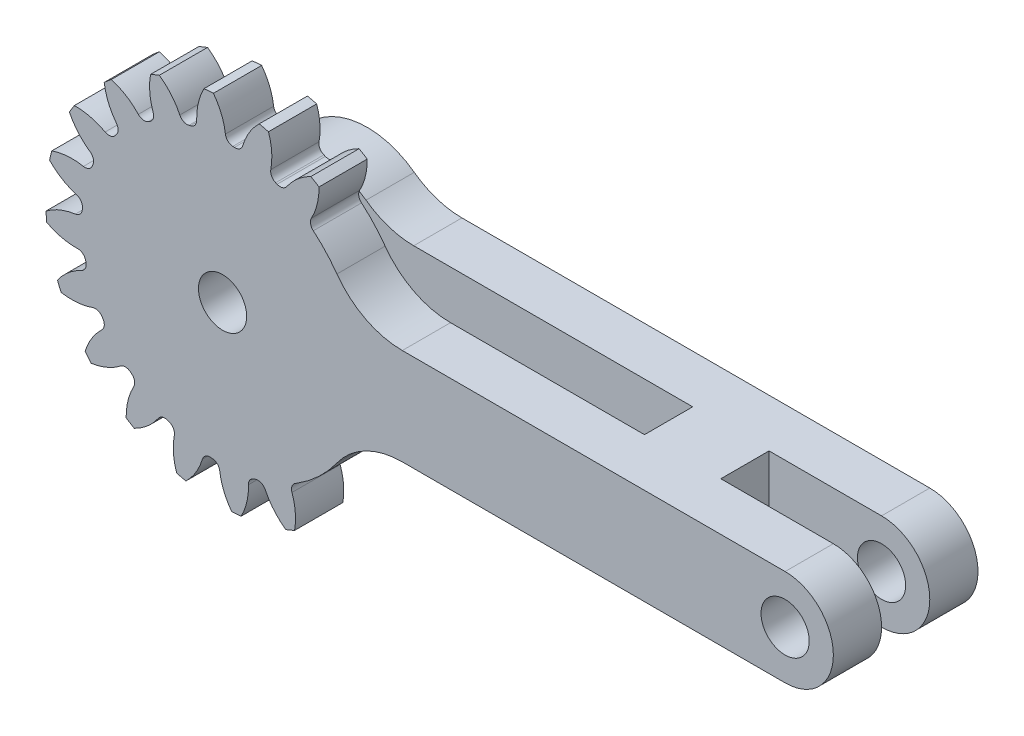
from build123d import *

# Parameters (mm, degrees)
ESTRUSIONE_ESTRUSIONE1_DEPTH         = 4.5
ESTRUSIONE_ESTRUSIONE1_DEPTH_BACK    = 4.5
SCHIZZO2_R                           = 8.75
SCHIZZO2_R_2                         = 1.5
ESTRUSIONE_ESTRUSIONE2_DEPTH         = 4.5
RACCORDO1_R                          = 0.5
RACCORDO2_R                          = 0.5
RIPETIZIONECIRCOLARE1_COUNT          = 20
RACCORDO1_OF_RIPETIZIONECIRCOLARE1_R = 0.5
RACCORDO2_OF_RIPETIZIONECIRCOLARE1_R = 0.5
ESTRUSIONE_ESTRUSIONE4_DEPTH         = 4.5
ESTRUSIONE_ESTRUSIONE4_DEPTH_BACK    = 4.5
SCHIZZO1_R                           = 1.5
TAGLIO_ESTRUSIONE2_DEPTH             = 15
TAGLIO_ESTRUSIONE2_DEPTH_BACK        = 15
SCHIZZO8_W                           = 10
SCHIZZO8_H                           = 3
SCHIZZO8_W_2                         = 35
TAGLIO_ESTRUSIONE3_DEPTH             = 3.3
TAGLIO_ESTRUSIONE4_START             = -3.3
TAGLIO_ESTRUSIONE4_DEPTH             = 3.3
RACCORDO3_R                          = 5
RACCORDO4_R                          = 5
RACCORDO5_R                          = 5
RACCORDO6_R                          = 5


with BuildPart() as part:
    # Schizzo2 → Estrusione-Estrusione1 (new, two sides: drawn at the far end of the back side and taken through both)
    with BuildSketch(Plane.XY.offset(-ESTRUSIONE_ESTRUSIONE1_DEPTH_BACK)):
        Circle(SCHIZZO2_R)
        Circle(SCHIZZO2_R_2, mode=Mode.SUBTRACT)
    extrude(amount=ESTRUSIONE_ESTRUSIONE1_DEPTH + ESTRUSIONE_ESTRUSIONE1_DEPTH_BACK)

    # Schizzo3 → Estrusione-Estrusione2 (add)
    with BuildSketch(Plane.XY):
        with BuildLine():
            ThreePointArc((-8.747468803, 0.210450818), (-8.72302667, -0.686517088), (-8.606851185, -1.576265422))
            ThreePointArc((-8.606851185, -1.576265422), (-9.80578703, -1.55009332), (-10.938929077, -1.157510536))
            ThreePointArc((-10.938929077, -1.157510536), (-10.966090671, -0.863050053), (-10.98532725, -0.567965858))
            ThreePointArc((-10.98532725, -0.567965858), (-9.927549539, -0.00295395), (-8.747468803, 0.210450818))
        make_face()
    estrusione_estrusione2 = extrude(amount=ESTRUSIONE_ESTRUSIONE2_DEPTH)

    # Raccordo1
    raccordo1_edges = [part.edges().sort_by_distance(p)[0] for p in [
        (-8.747468803, 0.210450818, 2.25),
    ]]
    fillet(raccordo1_edges, radius=RACCORDO1_R)

    # Raccordo2
    raccordo2_edges = [part.edges().sort_by_distance(p)[0] for p in [
        (-8.606851185, -1.576265422, 2.25),
    ]]
    fillet(raccordo2_edges, radius=RACCORDO2_R)

    # RipetizioneCircolare1: Estrusione-Estrusione2 ×20 about axis
    ripetizionecircolare1_axis = Axis((0, 0, -4.5), (0, 0, 1))
    for i in range(1, RIPETIZIONECIRCOLARE1_COUNT):
        add(estrusione_estrusione2.rotate(ripetizionecircolare1_axis, i * 360 / RIPETIZIONECIRCOLARE1_COUNT))

    # Raccordo1 of RipetizioneCircolare1
    raccordo1_of_ripetizionecircolare1_edges = [part.edges().sort_by_distance(p)[0] for p in [
        (-8.384370085, -2.502965896, 2.25),
        (-7.200550806, -4.971374869, 2.25),
        (-5.311891446, -6.953151032, 2.25),
        (-2.90326714, -8.254304326, 2.25),
        (-0.210450818, -8.747468803, 2.25),
        (2.502965896, -8.384370085, 2.25),
        (4.971374869, -7.200550806, 2.25),
        (6.953151032, -5.311891446, 2.25),
        (8.254304326, -2.90326714, 2.25),
        (8.747468803, -0.210450818, 2.25),
        (8.384370085, 2.502965896, 2.25),
        (7.200550806, 4.971374869, 2.25),
        (5.311891446, 6.953151032, 2.25),
        (2.90326714, 8.254304326, 2.25),
        (0.210450818, 8.747468803, 2.25),
        (-2.502965896, 8.384370085, 2.25),
        (-4.971374869, 7.200550806, 2.25),
        (-6.953151032, 5.311891446, 2.25),
        (-8.254304326, 2.90326714, 2.25),
    ]]
    fillet(raccordo1_of_ripetizionecircolare1_edges, radius=RACCORDO1_OF_RIPETIZIONECIRCOLARE1_R)

    # Raccordo2 of RipetizioneCircolare1
    raccordo2_of_ripetizionecircolare1_edges = [part.edges().sort_by_distance(p)[0] for p in [
        (-7.698509101, -4.158780785, 2.25),
        (-6.036583308, -6.334205709, 2.25),
        (-3.783754681, -7.889594445, 2.25),
        (-1.160545783, -8.672694707, 2.25),
        (1.576265422, -8.606851185, 2.25),
        (4.158780785, -7.698509101, 2.25),
        (6.334205709, -6.036583308, 2.25),
        (7.889594445, -3.783754681, 2.25),
        (8.672694707, -1.160545783, 2.25),
        (8.606851185, 1.576265422, 2.25),
        (7.698509101, 4.158780785, 2.25),
        (6.036583308, 6.334205709, 2.25),
        (3.783754681, 7.889594445, 2.25),
        (1.160545783, 8.672694707, 2.25),
        (-1.576265422, 8.606851185, 2.25),
        (-4.158780785, 7.698509101, 2.25),
        (-6.334205709, 6.036583308, 2.25),
        (-7.889594445, 3.783754681, 2.25),
        (-8.672694707, 1.160545783, 2.25),
    ]]
    fillet(raccordo2_of_ripetizionecircolare1_edges, radius=RACCORDO2_OF_RIPETIZIONECIRCOLARE1_R)

    # Schizzo1 → Estrusione-Estrusione4 (add, two sides: drawn at the far end of the back side and taken through both)
    with BuildSketch(Plane.XY.offset(-ESTRUSIONE_ESTRUSIONE4_DEPTH_BACK)):
        with BuildLine():
            ThreePointArc((35, -3), (38, 0), (35, 3))
            Line((35, 3), (0, 3))
            ThreePointArc((0, 3), (-3, 0), (0, -3))
            Line((0, -3), (35, -3))
        make_face()
        Circle(SCHIZZO1_R, mode=Mode.SUBTRACT)
        with Locations((35, 0)):
            Circle(SCHIZZO1_R, mode=Mode.SUBTRACT)
    extrude(amount=ESTRUSIONE_ESTRUSIONE4_DEPTH + ESTRUSIONE_ESTRUSIONE4_DEPTH_BACK)

    # Schizzo8 → Taglio-Estrusione2 (cut, two sides: drawn at the far end of the back side and taken through both)
    with BuildSketch(Plane(origin=(0, 3, 0), x_dir=(1, 0, 0), z_dir=(0, 1, 0)).offset(-TAGLIO_ESTRUSIONE2_DEPTH_BACK)):
        with Locations((33, 0)):
            Rectangle(SCHIZZO8_W, SCHIZZO8_H)
        with Locations((5.75, 0)):
            Rectangle(SCHIZZO8_W_2, SCHIZZO8_H)
    extrude(amount=TAGLIO_ESTRUSIONE2_DEPTH + TAGLIO_ESTRUSIONE2_DEPTH_BACK, mode=Mode.SUBTRACT)

    # Schizzo9 → Taglio-Estrusione3 (cut)
    with BuildSketch(Plane(origin=(0, 0, -4.5), x_dir=(-1, 0, 0), z_dir=(0, 0, -1))):
        with BuildLine():
            Line((-8.219641111, 3), (-3.919641111, 3))
            ThreePointArc((-3.919641111, 3), (4.935948383, 0), (-3.919641111, -3))
            Line((-3.919641111, -3), (-8.219641111, -3))
            ThreePointArc((-8.219641111, -3), (8.75, 0), (-8.219641111, 3))
        make_face()
    extrude(amount=-TAGLIO_ESTRUSIONE3_DEPTH, mode=Mode.SUBTRACT)

    # Schizzo10 → Taglio-Estrusione4 (cut)
    with BuildSketch(Plane.XY.offset(4.5).offset(TAGLIO_ESTRUSIONE4_START)):
        with BuildLine():
            Line((9.344633641, 3), (8.219641111, 3))
            ThreePointArc((8.219641111, 3), (7.201030237, 4.970680388), (5.719564246, 6.621864151))
            Line((5.719564246, 6.621864151), (8.634121218, 8.480947468))
            Line((8.634121218, 8.480947468), (11.50497977, 3.980191244))
            Line((11.50497977, 3.980191244), (9.344633641, 3))
        make_face()
        with BuildLine():
            Line((4.624902836, -7.427837758), (6.162751299, -9.897703457))
            Line((6.162751299, -9.897703457), (11.50497977, -6.571393916))
            Line((11.50497977, -6.571393916), (10.072960079, -3))
            Line((10.072960079, -3), (8.219641111, -3))
            ThreePointArc((8.219641111, -3), (6.793159361, -5.515023653), (4.624902836, -7.427837758))
        make_face()
    extrude(amount=TAGLIO_ESTRUSIONE4_DEPTH, mode=Mode.SUBTRACT)

    # Raccordo3
    raccordo3_edges = [part.edges().sort_by_distance(p)[0] for p in [
        (8.219641111, 3, 3),
    ]]
    fillet(raccordo3_edges, radius=RACCORDO3_R)

    # Raccordo4
    raccordo4_edges = [part.edges().sort_by_distance(p)[0] for p in [
        (8.219641111, -3, 3),
    ]]
    fillet(raccordo4_edges, radius=RACCORDO4_R)

    # Raccordo5
    raccordo5_edges = [part.edges().sort_by_distance(p)[0] for p in [
        (3.919641111, -3, -3),
    ]]
    fillet(raccordo5_edges, radius=RACCORDO5_R)

    # Raccordo6
    raccordo6_edges = [part.edges().sort_by_distance(p)[0] for p in [
        (3.919641111, 3, -3),
    ]]
    fillet(raccordo6_edges, radius=RACCORDO6_R)


solid = part.part
